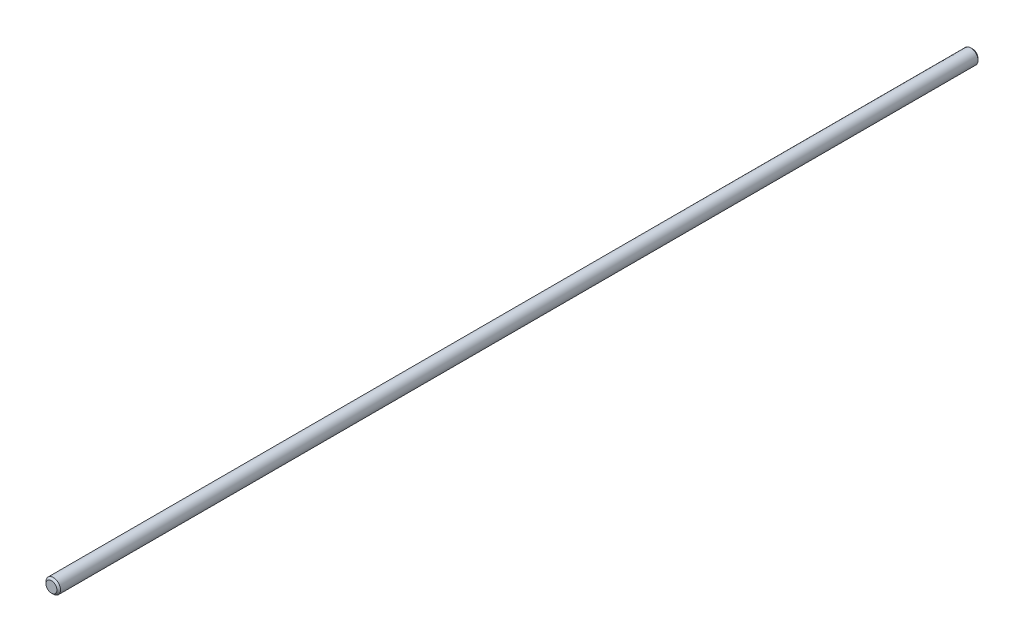
from build123d import *

# Parameters (mm, degrees)
SKETCH1_R           = 4
BOSS_EXTRUDE1_DEPTH = 507
CHAMFER1_SIZE       = 1


with BuildPart() as part:
    # Sketch1 → Boss-Extrude1 (new body)
    with BuildSketch(Plane.XY):
        Circle(SKETCH1_R)
    extrude(amount=BOSS_EXTRUDE1_DEPTH)

    # Chamfer1
    chamfer1_edges = [part.edges().sort_by_distance(p)[0] for p in [
        (-4, 0, 0),
        (-4, 0, 507),
    ]]
    chamfer(chamfer1_edges, length=CHAMFER1_SIZE)


solid = part.part
